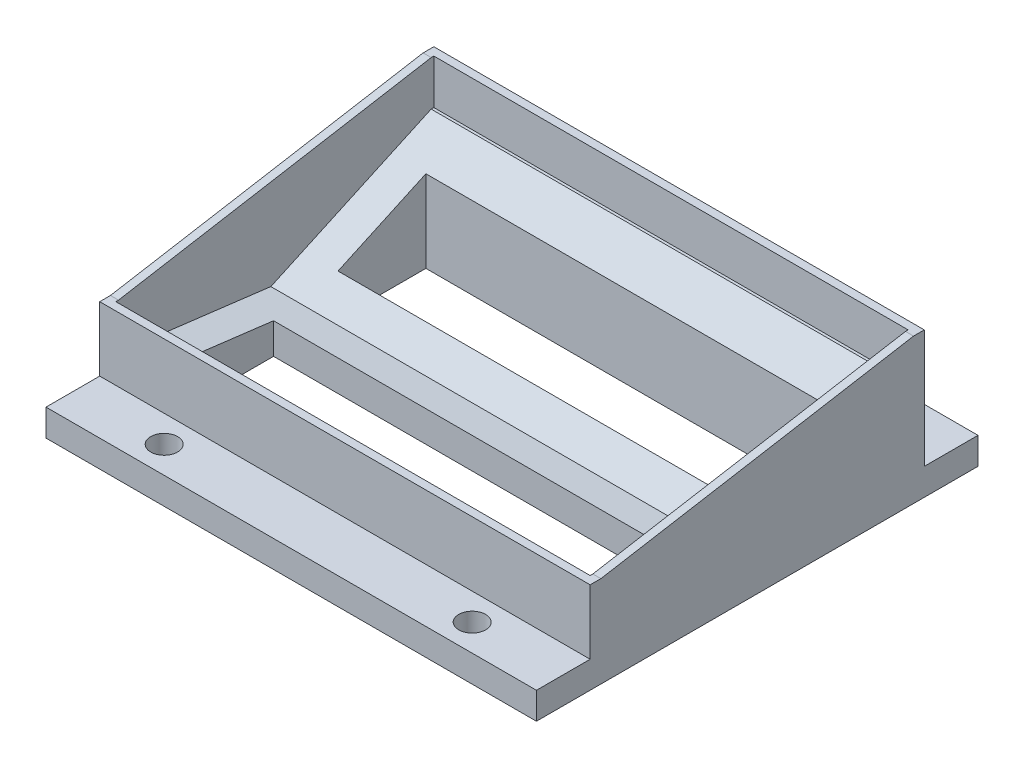
from build123d import *

# Parameters (mm, degrees)
BOSS_EXTRUDE1_DEPTH  = 87.3
CUT_EXTRUDE1_REACH   = 7
SKETCH2_R            = 2.5
SKETCH3_W            = 75.3
SKETCH3_H            = 16.36
CUT_EXTRUDE2_DEPTH   = 19.693329973
SKETCH4_W            = 2
SKETCH4_H            = 12
SKETCH4_H_2          = 22
BOSS_EXTRUDE2_DEPTH  = 87.3
BOSS_EXTRUDE16_DEPTH = 2
LPATTERN1_COUNT      = 2
LPATTERN1_PITCH      = 89.3
CUT_EXTRUDE4_DEPTH   = 0.5
CUT_EXTRUDE5_DEPTH   = 0.5
SKETCH14_W           = 88.3
SKETCH14_H           = 8.306670027
CUT_EXTRUDE6_DEPTH   = 0.5
SKETCH15_W           = 88.3
SKETCH15_H           = 8.482653923
CUT_EXTRUDE7_DEPTH   = 0.5


with BuildPart() as part:
    # Sketch1 → Boss-Extrude1 (new body)
    with BuildSketch(Plane(origin=(0, 0, 0), x_dir=(0, 0, -1), z_dir=(1, 0, 0))):
        Polygon((-73.551459735, 26.94681652), (-43.711459735, 40.640146493), (-43.711459735, 26.94681652), (-31.711459735, 26.94681652), (-31.711459735, 21.94681652), (-113.911459735, 21.94681652), (-113.911459735, 26.94681652), (-101.911459735, 26.94681652), (-101.911459735, 30.464162597), align=None)
    extrude(amount=BOSS_EXTRUDE1_DEPTH)

    # Sketch2 → Cut-Extrude1 (cut, up to next)
    with BuildSketch(Plane(origin=(0, 26.94681652, 0), x_dir=(1, 0, 0), z_dir=(0, 1, 0)), mode=Mode.PRIVATE) as cut_extrude1_sk1:
        with Locations((15, -36.711459735)):
            Circle(SKETCH2_R)
    cut_extrude1_tool1 = extrude(cut_extrude1_sk1.sketch, amount=-CUT_EXTRUDE1_REACH, mode=Mode.PRIVATE) & part.part
    add(cut_extrude1_tool1.solids().sort_by_distance((15, 26.946817, 36.71146))[0], mode=Mode.SUBTRACT)
    # Sketch2 → Cut-Extrude1 (cut, up to next)
    with BuildSketch(Plane(origin=(0, 26.94681652, 0), x_dir=(1, 0, 0), z_dir=(0, 1, 0)), mode=Mode.PRIVATE) as cut_extrude1_sk2:
        with Locations((72.333370453, -36.711459735)):
            Circle(SKETCH2_R)
    cut_extrude1_tool2 = extrude(cut_extrude1_sk2.sketch, amount=-CUT_EXTRUDE1_REACH, mode=Mode.PRIVATE) & part.part
    add(cut_extrude1_tool2.solids().sort_by_distance((72.33337, 26.946817, 36.71146))[0], mode=Mode.SUBTRACT)
    # Sketch2 → Cut-Extrude1 (cut, up to next)
    with BuildSketch(Plane(origin=(0, 26.94681652, 0), x_dir=(1, 0, 0), z_dir=(0, 1, 0)), mode=Mode.PRIVATE) as cut_extrude1_sk3:
        with Locations((72.333370453, -108.911459735)):
            Circle(SKETCH2_R)
    cut_extrude1_tool3 = extrude(cut_extrude1_sk3.sketch, amount=-CUT_EXTRUDE1_REACH, mode=Mode.PRIVATE) & part.part
    add(cut_extrude1_tool3.solids().sort_by_distance((72.33337, 26.946817, 108.91146))[0], mode=Mode.SUBTRACT)
    # Sketch2 → Cut-Extrude1 (cut, up to next)
    with BuildSketch(Plane(origin=(0, 26.94681652, 0), x_dir=(1, 0, 0), z_dir=(0, 1, 0)), mode=Mode.PRIVATE) as cut_extrude1_sk4:
        with Locations((15, -108.911459735)):
            Circle(SKETCH2_R)
    cut_extrude1_tool4 = extrude(cut_extrude1_sk4.sketch, amount=-CUT_EXTRUDE1_REACH, mode=Mode.PRIVATE) & part.part
    add(cut_extrude1_tool4.solids().sort_by_distance((15, 26.946817, 108.91146))[0], mode=Mode.SUBTRACT)

    # Sketch3 → Cut-Extrude2 (cut, through all)
    with BuildSketch(Plane.XZ.offset(-21.94681652)):
        with Locations((43.65, 87.731459735)):
            Rectangle(SKETCH3_W, SKETCH3_H)
        with Locations((43.65, 59.371459735)):
            Rectangle(SKETCH3_W, SKETCH3_H)
    extrude(amount=-CUT_EXTRUDE2_DEPTH, mode=Mode.SUBTRACT)

    # Sketch4 → Boss-Extrude2 (add, through all)
    with BuildSketch(Plane(origin=(87.3, 0, 0), x_dir=(0, 0, -1), z_dir=(1, 0, 0))):
        with Locations((-102.911459735, 32.94681652)):
            Rectangle(SKETCH4_W, SKETCH4_H)
        with Locations((-42.711459735, 37.94681652)):
            Rectangle(SKETCH4_W, SKETCH4_H_2)
    extrude(amount=-BOSS_EXTRUDE2_DEPTH)

    # Sketch8 → Boss-Extrude16 (add)
    with BuildSketch(Plane(origin=(87.3, 0, 0), x_dir=(0, 0, -1), z_dir=(1, 0, 0))):
        Polygon((-103.911459735, 38.94681652), (-101.911459735, 38.94681652), (-43.711459735, 48.94681652), (-41.711459735, 48.94681652), (-41.711459735, 26.94681652), (-31.711459735, 26.94681652), (-31.711459735, 21.94681652), (-113.911459735, 21.94681652), (-113.911459735, 26.94681652), (-103.911459735, 26.94681652), align=None)
    boss_extrude16 = extrude(amount=BOSS_EXTRUDE16_DEPTH)

    # LPattern1: Boss-Extrude16 ×2
    with Locations(*[(-i * LPATTERN1_PITCH, 0, 0) for i in range(1, LPATTERN1_COUNT)]):
        add(boss_extrude16)

    # Sketch12 → Cut-Extrude4 (cut)
    with BuildSketch(Plane(origin=(0, 0, 0), x_dir=(0, 0, -1), z_dir=(1, 0, 0))):
        Polygon((-43.711459735, 48.94681652), (-43.711459735, 40.640146493), (-73.551459735, 26.94681652), (-101.911459735, 30.464162597), (-101.911459735, 38.94681652), align=None)
    extrude(amount=-CUT_EXTRUDE4_DEPTH, mode=Mode.SUBTRACT)

    # Sketch13 → Cut-Extrude5 (cut)
    with BuildSketch(Plane.ZY.offset(-87.3)):
        Polygon((43.711459735, 40.640146493), (43.711459735, 48.94681652), (101.911459735, 38.94681652), (101.911459735, 30.464162597), (73.551459735, 26.94681652), align=None)
    extrude(amount=-CUT_EXTRUDE5_DEPTH, mode=Mode.SUBTRACT)

    # Sketch14 → Cut-Extrude6 (cut)
    with BuildSketch(Plane.XY.offset(43.711459735)):
        with Locations((43.65, 44.793481507)):
            Rectangle(SKETCH14_W, SKETCH14_H)
    extrude(amount=-CUT_EXTRUDE6_DEPTH, mode=Mode.SUBTRACT)

    # Sketch15 → Cut-Extrude7 (cut)
    with BuildSketch(Plane(origin=(0, 0, 101.911459735), x_dir=(-1, 0, 0), z_dir=(0, 0, -1))):
        with Locations((-43.65, 34.705489559)):
            Rectangle(SKETCH15_W, SKETCH15_H)
    extrude(amount=-CUT_EXTRUDE7_DEPTH, mode=Mode.SUBTRACT)


solid = part.part
